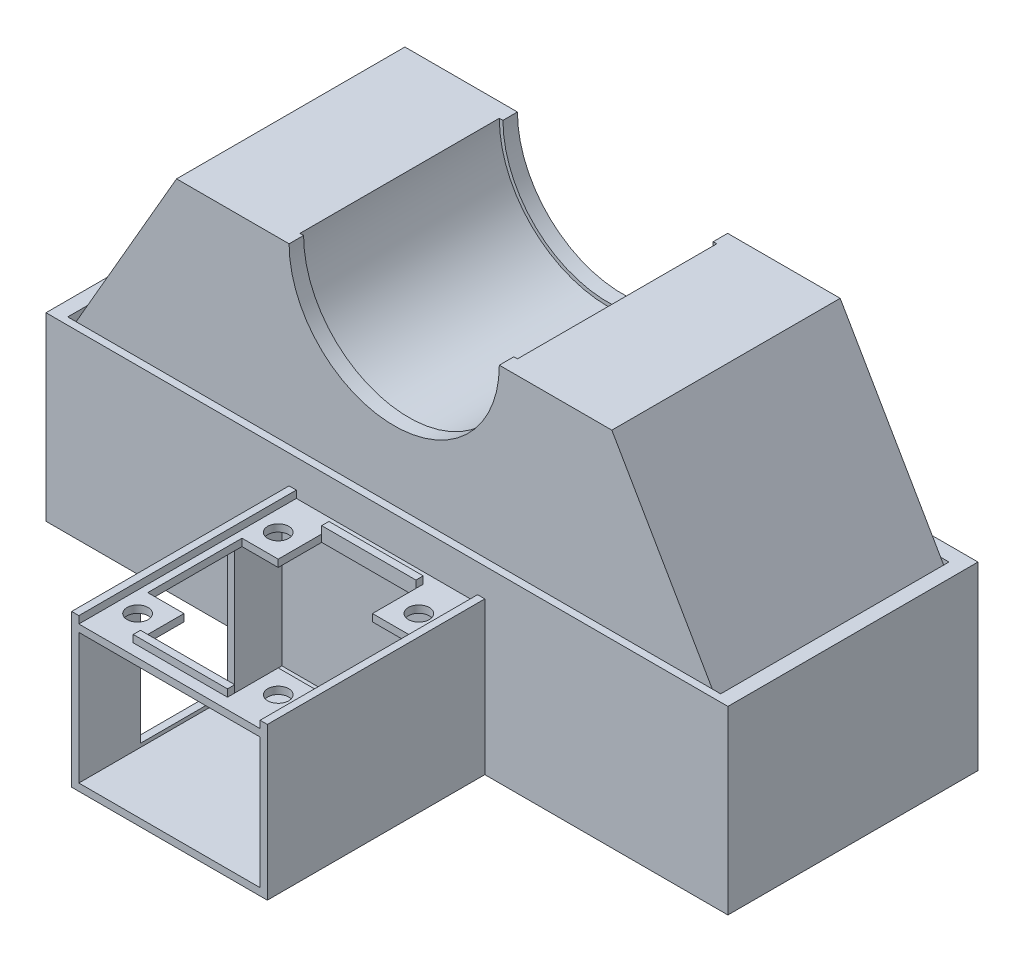
from build123d import *

# Parameters (mm, degrees)
BOSS_EXTRUDE1_DEPTH  = 27.5
BOSS_EXTRUDE2_DEPTH  = 2
BOSS_EXTRUDE3_DEPTH  = 2
ENCODER_RAIL_W       = 23
ENCODER_RAIL_H       = 1
ENCODER_RAIL_W_2     = 4
ENCODER_RAIL_H_2     = 4
BOSS_EXTRUDE6_DEPTH  = 31.5
SKETCH3_W            = 94.066641994
SKETCH3_H            = 24.92
BOSS_EXTRUDE7_DEPTH  = 2
SKETCH4_W            = 94.066641994
SKETCH4_H            = 24.92
BOSS_EXTRUDE8_DEPTH  = 1
SKETCH6_W            = 90.066641994
SKETCH6_H            = 30.5
CUT_EXTRUDE1_DEPTH   = 17.92
BOSS_EXTRUDE10_START = 1
ENCODER_RAIL_9_W     = 4
ENCODER_RAIL_9_H     = 4
ENCODER_RAIL_9_W_2   = 1
ENCODER_RAIL_9_H_2   = 1
BOSS_EXTRUDE10_DEPTH = 2
ENCODER_RAIL_10_W    = 4
ENCODER_RAIL_10_H    = 4
CUT_EXTRUDE2_DEPTH   = 1
ENCODER_RAIL_11_W    = 4
ENCODER_RAIL_11_H    = 4
BOSS_EXTRUDE11_DEPTH = 1
SKETCH8_W            = 25
SKETCH8_H            = 18
BOSS_EXTRUDE12_DEPTH = 28
SKETCH9_R            = 1.45
SKETCH9_W            = 13
SKETCH9_H            = 1
CUT_EXTRUDE4_DEPTH   = 1
SKETCH9_4_W          = 13
SKETCH9_4_H          = 1
BOSS_EXTRUDE13_DEPTH = 1
SKETCH11_W           = 13
SKETCH11_H           = 17
CUT_EXTRUDE5_DEPTH   = 1


with BuildPart() as part:
    # Frame → Boss-Extrude1 (new body)
    with BuildSketch(Plane.XY):
        with BuildLine():
            Line((-45.033320997, -26), (45.033320997, -26))
            Line((45.033320997, -26), (30.022213998, 0))
            Line((30.022213998, 0), (18, 0))
            ThreePointArc((18, 0), (0, -18), (-18, 0))
            Line((-18, 0), (-30.022213998, 0))
            Line((-30.022213998, 0), (-45.033320997, -26))
        make_face()
        with BuildLine():
            ThreePointArc((-18, 0), (0, -18), (18, 0))
            Line((18, 0), (15, 0))
            ThreePointArc((15, 0), (0, -15), (-15, 0))
            Line((-15, 0), (-18, 0))
        make_face()
    extrude(amount=BOSS_EXTRUDE1_DEPTH)

    # lip → Boss-Extrude2 (add)
    with BuildSketch(Plane.XY.offset(27.5)):
        with BuildLine():
            Line((45.033320997, -26), (30.022213998, 0))
            Line((30.022213998, 0), (15, 0))
            ThreePointArc((15, 0), (0, -15), (-15, 0))
            Line((-15, 0), (-30.022213998, 0))
            Line((-30.022213998, 0), (-45.033320997, -26))
            Line((-45.033320997, -26), (45.033320997, -26))
        make_face()
        with BuildLine():
            ThreePointArc((14.5, 0), (0, -14.5), (-14.5, 0))
            Line((-14.5, 0), (-15, 0))
            ThreePointArc((-15, 0), (0, -15), (15, 0))
            Line((15, 0), (14.5, 0))
        make_face()
    extrude(amount=BOSS_EXTRUDE2_DEPTH)

    # lip2 → Boss-Extrude3 (add)
    with BuildSketch(Plane(origin=(0, 0, 0), x_dir=(-1, 0, 0), z_dir=(0, 0, -1))):
        with BuildLine():
            ThreePointArc((15, 0), (0, -15), (-15, 0))
            Line((-15, 0), (-30.022213998, 0))
            Line((-30.022213998, 0), (-45.033320997, -26))
            Line((-45.033320997, -26), (45.033320997, -26))
            Line((45.033320997, -26), (30.022213998, 0))
            Line((30.022213998, 0), (15, 0))
        make_face()
        with BuildLine():
            Line((-14.5, 0), (-15, 0))
            ThreePointArc((-15, 0), (0, -15), (15, 0))
            Line((15, 0), (14.5, 0))
            ThreePointArc((14.5, 0), (0, -14.5), (-14.5, 0))
        make_face()
    extrude(amount=BOSS_EXTRUDE3_DEPTH)


with BuildPart() as body_2:
    # Encoder Rail → Boss-Extrude6 (new body, through all)
    with BuildSketch(Plane.XY.offset(29.5)):
        Polygon((47.033320997, -48.92), (47.033320997, -24), (45.033320997, -24), (45.033320997, -26), (-45.033320997, -26), (-45.033320997, -24), (-47.033320997, -24), (-47.033320997, -48.92), align=None)
        with Locations((0, -29.42)):
            Rectangle(ENCODER_RAIL_W, ENCODER_RAIL_H, mode=Mode.SUBTRACT)
        with Locations((0, -38.92)):
            Rectangle(ENCODER_RAIL_W_2, ENCODER_RAIL_H_2, mode=Mode.SUBTRACT)
    extrude(amount=-BOSS_EXTRUDE6_DEPTH)

    # Sketch3 → Boss-Extrude7 (add)
    with BuildSketch(Plane(origin=(0, 0, -2), x_dir=(-1, 0, 0), z_dir=(0, 0, -1))):
        with Locations((0, -36.46)):
            Rectangle(SKETCH3_W, SKETCH3_H)
    extrude(amount=BOSS_EXTRUDE7_DEPTH)

    # Sketch4 → Boss-Extrude8 (add)
    with BuildSketch(Plane.XY.offset(29.5)):
        with Locations((0, -36.46)):
            Rectangle(SKETCH4_W, SKETCH4_H)
    extrude(amount=BOSS_EXTRUDE8_DEPTH)

    # Sketch6 → Cut-Extrude1 (cut)
    with BuildSketch(Plane(origin=(0, -48.92, 0), x_dir=(-1, 0, 0), z_dir=(0, -1, 0))):
        with Locations((0, -13.25)):
            Rectangle(SKETCH6_W, SKETCH6_H)
    extrude(amount=-CUT_EXTRUDE1_DEPTH, mode=Mode.SUBTRACT)

    # Encoder Rail_10 → Cut-Extrude2 (cut)
    with BuildSketch(Plane.XY.offset(29.5)):
        with Locations((0, -38.92)):
            Rectangle(ENCODER_RAIL_10_W, ENCODER_RAIL_10_H)
    extrude(amount=CUT_EXTRUDE2_DEPTH, mode=Mode.SUBTRACT)


with BuildPart() as body_3:
    # Encoder Rail_9 → Boss-Extrude10 (new body)
    with BuildSketch(Plane.XY.offset(29.5).offset(BOSS_EXTRUDE10_START)):
        Polygon((12.5, -48.92), (13.5, -48.92), (13.5, -28.92), (12.5, -28.92), (12.5, -29.92), align=None)
        Polygon((-12.5, -29.92), (-12.5, -48.92), (12.5, -48.92), (12.5, -29.92), (11.5, -29.92), (-11.5, -29.92), align=None)
        with Locations((0, -38.92)):
            Rectangle(ENCODER_RAIL_9_W, ENCODER_RAIL_9_H, mode=Mode.SUBTRACT)
        with Locations((0, -38.92)):
            Rectangle(ENCODER_RAIL_9_W, ENCODER_RAIL_9_H)
        Polygon((-13.5, -28.92), (-13.5, -48.92), (-12.5, -48.92), (-12.5, -29.92), (-12.5, -28.92), align=None)
        with Locations((-13, -28.42)):
            Rectangle(ENCODER_RAIL_9_W_2, ENCODER_RAIL_9_H_2)
        with Locations((-12, -29.42)):
            Rectangle(ENCODER_RAIL_9_W_2, ENCODER_RAIL_9_H_2)
        Polygon((11.5, -28.92), (0, -28.92), (-11.5, -28.92), (-11.5, -29.92), (11.5, -29.92), align=None)
        with Locations((12, -29.42)):
            Rectangle(ENCODER_RAIL_9_W_2, ENCODER_RAIL_9_H_2)
        with Locations((13, -28.42)):
            Rectangle(ENCODER_RAIL_9_W_2, ENCODER_RAIL_9_H_2)
    extrude(amount=BOSS_EXTRUDE10_DEPTH)

    # Encoder Rail_11 → Boss-Extrude11 (add)
    with BuildSketch(Plane.XY.offset(29.5)):
        with Locations((0, -38.92)):
            Rectangle(ENCODER_RAIL_11_W, ENCODER_RAIL_11_H)
    extrude(amount=BOSS_EXTRUDE11_DEPTH)

    # Sketch8 → Boss-Extrude12 (add)
    with BuildSketch(Plane.XY.offset(32.5)):
        Polygon((-13.5, -48.92), (13.5, -48.92), (13.5, -27.92), (12.5, -27.92), (12.5, -28.92), (-12.5, -28.92), (-12.5, -27.92), (-13.5, -27.92), align=None)
        with Locations((0, -38.92)):
            Rectangle(SKETCH8_W, SKETCH8_H, mode=Mode.SUBTRACT)
    extrude(amount=BOSS_EXTRUDE12_DEPTH)

    # Sketch9 → Cut-Extrude4 (cut)
    with BuildSketch(Plane(origin=(0, -28.92, 0), x_dir=(1, 0, 0), z_dir=(0, 1, 0))):
        Polygon((-6.5, -39), (-11.5, -39), (-11.5, -52), (-6.5, -52), (-6.5, -57), (6.5, -57), (6.5, -52), (11.5, -52), (11.5, -39), (6.5, -39), (6.5, -34), (-6.5, -34), align=None)
        with Locations((9.7, -55.2)):
            Circle(SKETCH9_R)
        with Locations((-9.7, -55.2)):
            Circle(SKETCH9_R)
        with Locations((-9.7, -35.8)):
            Circle(SKETCH9_R)
        with Locations((9.7, -35.8)):
            Circle(SKETCH9_R)
        with Locations((0, -57.5)):
            Rectangle(SKETCH9_W, SKETCH9_H)
        with Locations((0, -33.5)):
            Rectangle(SKETCH9_W, SKETCH9_H)
    extrude(amount=-CUT_EXTRUDE4_DEPTH, mode=Mode.SUBTRACT)

    # Sketch9_4 → Boss-Extrude13 (add)
    with BuildSketch(Plane(origin=(0, -28.92, 0), x_dir=(1, 0, 0), z_dir=(0, 1, 0))):
        with Locations((0, -32.5)):
            Rectangle(SKETCH9_4_W, SKETCH9_4_H)
        with Locations((0, -58.5)):
            Rectangle(SKETCH9_4_W, SKETCH9_4_H)
    extrude(amount=BOSS_EXTRUDE13_DEPTH)

    # Sketch11 → Cut-Extrude5 (cut)
    with BuildSketch(Plane.ZY.offset(13.5)):
        with Locations((45.5, -38.92)):
            Rectangle(SKETCH11_W, SKETCH11_H)
    extrude(amount=-CUT_EXTRUDE5_DEPTH, mode=Mode.SUBTRACT)


solid = Compound([part.part, body_2.part, body_3.part])
